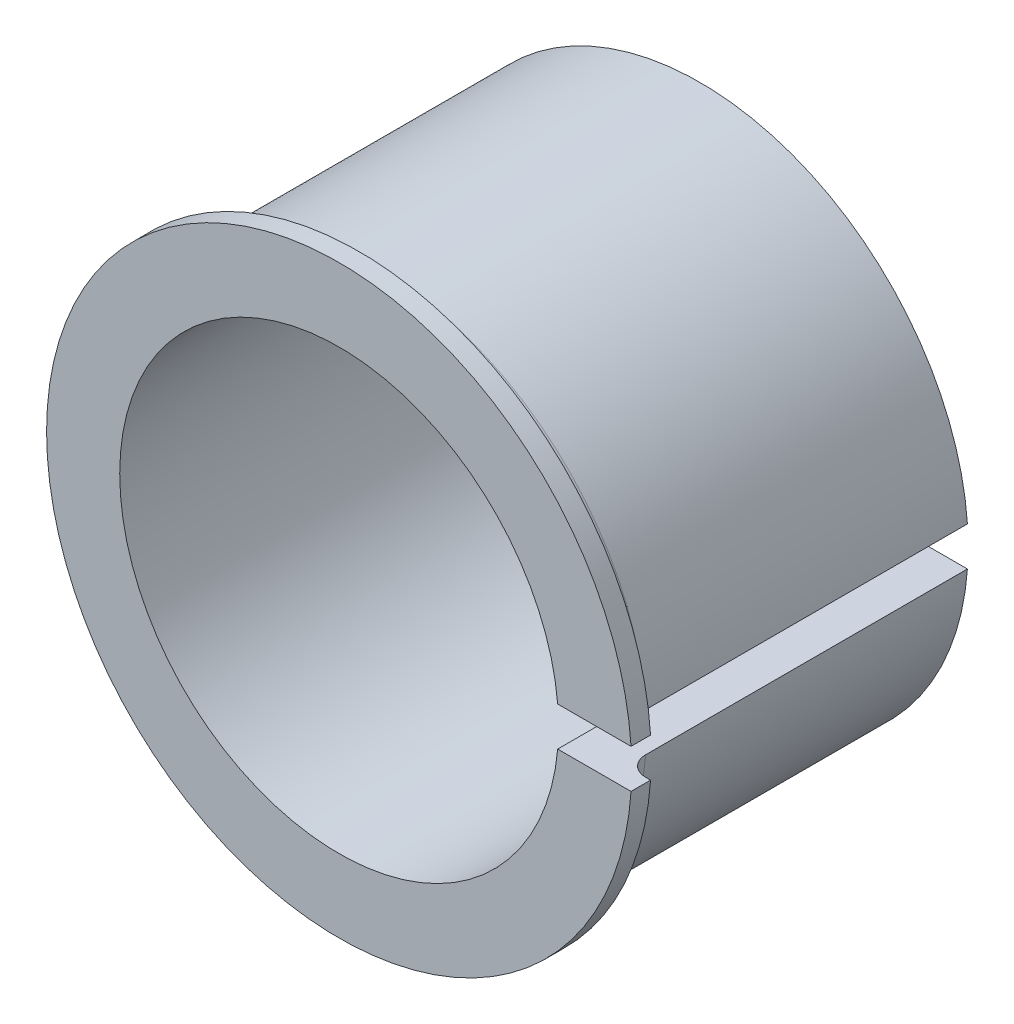
from build123d import *

# Parameters (mm, degrees)
EXTRUDE_1_DEPTH = 35
EXTRUDE_2_DEPTH = 2
FILLET_1_R      = 2


with BuildPart() as part:
    # Эскиз1 → Бобышка-Вытянуть1 (new body)
    with BuildSketch(Plane.XY):
        with BuildLine():
            Line((22.410934831, 2), (27.427176304, 2))
            ThreePointArc((27.427176304, 2), (-27.5, 0), (27.427176304, -2))
            Line((27.427176304, -2), (22.410934831, -2))
            ThreePointArc((22.410934831, -2), (-22.5, 0), (22.410934831, 2))
        make_face()
    extrude(amount=EXTRUDE_1_DEPTH)

    # Эскиз2 → Бобышка-Вытянуть2 (add)
    with BuildSketch(Plane.XY.offset(35)):
        with BuildLine():
            Line((22.410934831, 2), (29.933259094, 2))
            ThreePointArc((29.933259094, 2), (-30, 0), (29.933259094, -2))
            Line((29.933259094, -2), (22.410934831, -2))
            ThreePointArc((22.410934831, -2), (-22.5, 0), (22.410934831, 2))
        make_face()
    extrude(amount=EXTRUDE_2_DEPTH)

    # Скругление1
    fillet_1_edges = [part.edges().sort_by_distance(p)[0] for p in [
        (-27.5, 0, 35),
    ]]
    fillet(fillet_1_edges, radius=FILLET_1_R)


solid = part.part
